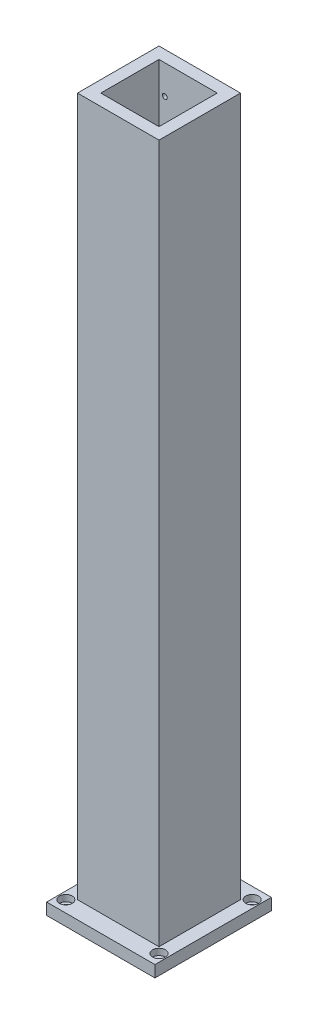
from build123d import *

# Parameters (mm, degrees)
SKETCH1_W             = 93
SKETCH1_H             = 100
BOSS_EXTRUDE1_DEPTH   = 10
SKETCH7_W             = 70
SKETCH7_H             = 70
SKETCH7_W_2           = 50
SKETCH7_H_2           = 50
BOSS_EXTRUDE4_DEPTH   = 600
M5_TAPPED_HOLE1_D     = 4.2
M5_TAPPED_HOLE1_DEPTH = 12.4
M5_TAPPED_HOLE1_TIP   = 1.2618073
SKETCH11_R            = 2.75
CUT_EXTRUDE1_DEPTH    = 11
SKETCH12_R            = 5.5
CUT_EXTRUDE2_DEPTH    = 5.5


with BuildPart() as part:
    # Sketch1 → Boss-Extrude1 (new body)
    with BuildSketch(Plane(origin=(0, 0, 0), x_dir=(1, 0, 0), z_dir=(0, 1, 0))):
        Rectangle(SKETCH1_W, SKETCH1_H)
    extrude(amount=BOSS_EXTRUDE1_DEPTH)

    # Sketch7 → Boss-Extrude4 (add)
    with BuildSketch(Plane(origin=(0, 10, 0), x_dir=(1, 0, 0), z_dir=(0, 1, 0))):
        Rectangle(SKETCH7_W, SKETCH7_H)
        Rectangle(SKETCH7_W_2, SKETCH7_H_2, mode=Mode.SUBTRACT)
    extrude(amount=BOSS_EXTRUDE4_DEPTH)

    # M5 Tapped Hole1
    with Locations(Plane(origin=(0, 0, -35), x_dir=(-1, 0, 0), z_dir=(0, 0, -1))):
        with Locations((-20, 585), (20, 585), (20, 555), (-20, 555)):
            Hole(M5_TAPPED_HOLE1_D / 2, depth=M5_TAPPED_HOLE1_DEPTH)
            with Locations((0, 0, -(M5_TAPPED_HOLE1_DEPTH + M5_TAPPED_HOLE1_TIP / 2))):  # 118° drill point
                Cone(0, M5_TAPPED_HOLE1_D / 2, M5_TAPPED_HOLE1_TIP, mode=Mode.SUBTRACT)

    # Sketch11 → Cut-Extrude1 (cut, through all)
    with BuildSketch(Plane(origin=(0, 10, 0), x_dir=(1, 0, 0), z_dir=(0, 1, 0))):
        with Locations((-40, 40)):
            Circle(SKETCH11_R)
        with Locations((-40, -40)):
            Circle(SKETCH11_R)
        with Locations((40, -40)):
            Circle(SKETCH11_R)
        with Locations((40, 40)):
            Circle(SKETCH11_R)
    extrude(amount=-CUT_EXTRUDE1_DEPTH, mode=Mode.SUBTRACT)

    # Sketch12 → Cut-Extrude2 (cut)
    with BuildSketch(Plane(origin=(0, 10, 0), x_dir=(1, 0, 0), z_dir=(0, 1, 0))):
        with Locations((-40, 40)):
            Circle(SKETCH12_R)
        with Locations((40, 40)):
            Circle(SKETCH12_R)
        with Locations((40, -40)):
            Circle(SKETCH12_R)
        with Locations((-40, -40)):
            Circle(SKETCH12_R)
    extrude(amount=-CUT_EXTRUDE2_DEPTH, mode=Mode.SUBTRACT)


solid = part.part
